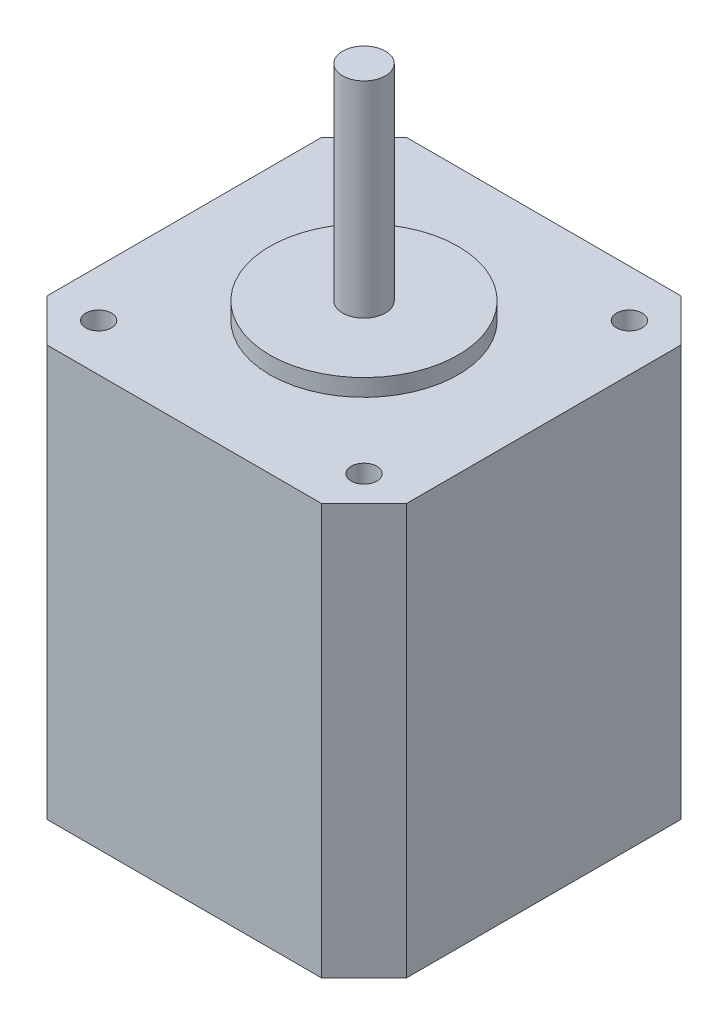
from build123d import *

# Parameters (mm, degrees)
SKETCH1_W           = 42
SKETCH1_H           = 42
BOSS_EXTRUDE1_DEPTH = 48
SKETCH5_R           = 11
BOSS_EXTRUDE4_DEPTH = 2
SKETCH6_R           = 2.5
BOSS_EXTRUDE5_DEPTH = 24
SKETCH8_R           = 1.5
CUT_EXTRUDE1_DEPTH  = 4.5
CUT_EXTRUDE2_DEPTH  = 49


with BuildPart() as part:
    # Sketch1 → Boss-Extrude1 (new body)
    with BuildSketch(Plane(origin=(0, 0, 0), x_dir=(1, 0, 0), z_dir=(0, 1, 0))):
        with Locations((21, 21)):
            Rectangle(SKETCH1_W, SKETCH1_H)
    extrude(amount=BOSS_EXTRUDE1_DEPTH)

    # Sketch5 → Boss-Extrude4 (add)
    with BuildSketch(Plane(origin=(0, 48, 0), x_dir=(1, 0, 0), z_dir=(0, 1, 0))):
        with Locations((21, 21)):
            Circle(SKETCH5_R)
    extrude(amount=BOSS_EXTRUDE4_DEPTH)

    # Sketch6 → Boss-Extrude5 (add)
    with BuildSketch(Plane(origin=(0, 50, 0), x_dir=(1, 0, 0), z_dir=(0, 1, 0))):
        with Locations((21, 21)):
            Circle(SKETCH6_R)
    extrude(amount=BOSS_EXTRUDE5_DEPTH)

    # Sketch8 → Cut-Extrude1 (cut)
    with BuildSketch(Plane(origin=(0, 48, 0), x_dir=(1, 0, 0), z_dir=(0, 1, 0))):
        with Locations((36.5, 5.5)):
            Circle(SKETCH8_R)
        with Locations((36.5, 36.5)):
            Circle(SKETCH8_R)
        with Locations((5.5, 5.5)):
            Circle(SKETCH8_R)
        with Locations((5.5, 36.5)):
            Circle(SKETCH8_R)
    extrude(amount=-CUT_EXTRUDE1_DEPTH, mode=Mode.SUBTRACT)

    # Sketch9 → Cut-Extrude2 (cut, through all)
    with BuildSketch(Plane(origin=(0, 48, 0), x_dir=(1, 0, 0), z_dir=(0, 1, 0))):
        Polygon((0, 4.949747468), (4.949747468, 0), (0, 0), align=None)
        Polygon((37.050252532, 0), (42, 4.949747468), (42, 0), align=None)
        Polygon((37.050252532, 42), (42, 37.050252532), (42, 42), align=None)
        Polygon((0, 37.050252532), (4.949747468, 42), (0, 42), align=None)
    extrude(amount=-CUT_EXTRUDE2_DEPTH, mode=Mode.SUBTRACT)


solid = part.part
